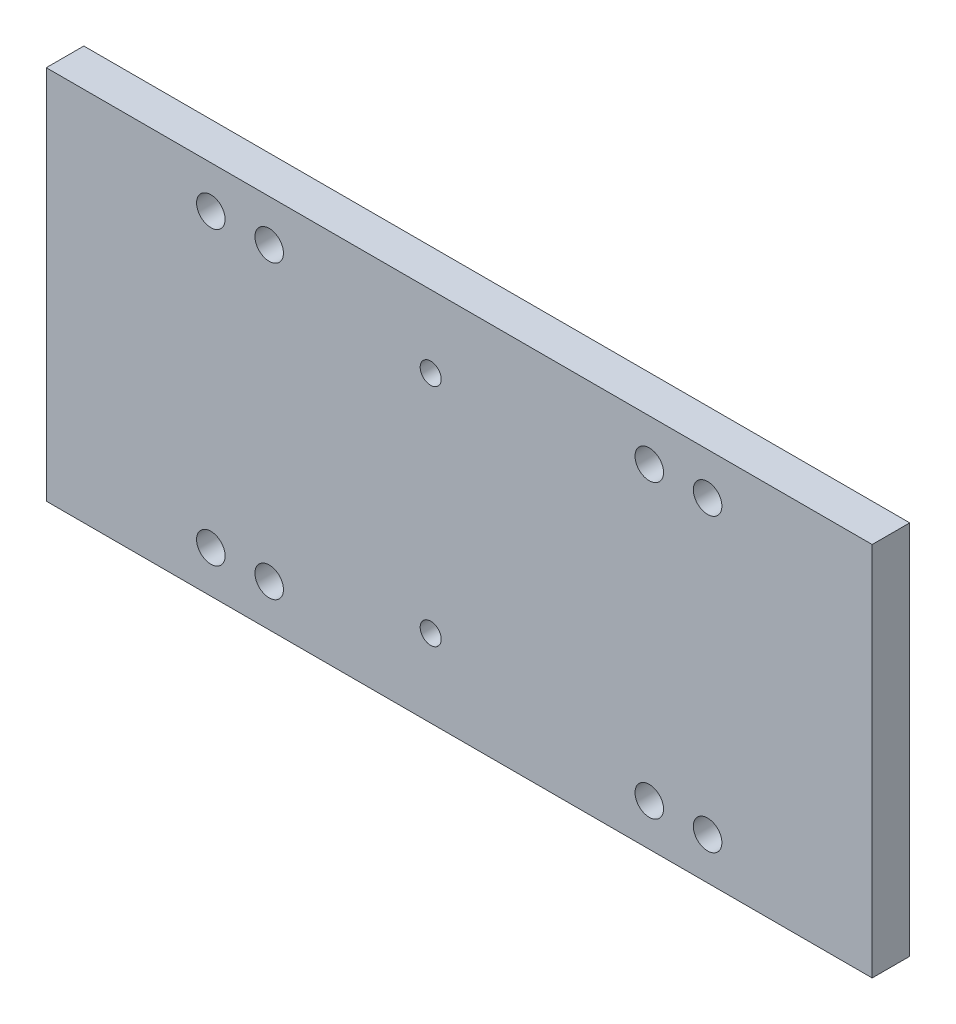
from build123d import *

# Parameters (mm, degrees)
SKETCH1_W           = 139.7
SKETCH1_H           = 63.5
BOSS_EXTRUDE1_DEPTH = 6.35
SKETCH2_R           = 1.778
CUT_EXTRUDE1_DEPTH  = 6.35
SKETCH3_R           = 2.413
CUT_EXTRUDE2_DEPTH  = 6.35


with BuildPart() as part:
    # Sketch1 → Boss-Extrude1 (new body)
    with BuildSketch(Plane.XY):
        with Locations((69.85, 31.75)):
            Rectangle(SKETCH1_W, SKETCH1_H)
    extrude(amount=BOSS_EXTRUDE1_DEPTH)

    # Sketch2 → Cut-Extrude1 (cut)
    with BuildSketch(Plane(origin=(0, 0, 0), x_dir=(-1, 0, 0), z_dir=(0, 0, -1))):
        with Locations((-65.024, 13.15775)):
            Circle(SKETCH2_R)
        with Locations((-65.024, 51.25775)):
            Circle(SKETCH2_R)
    extrude(amount=-CUT_EXTRUDE1_DEPTH, mode=Mode.SUBTRACT)

    # Sketch3 → Cut-Extrude2 (cut)
    with BuildSketch(Plane(origin=(0, 0, 0), x_dir=(-1, 0, 0), z_dir=(0, 0, -1))):
        with Locations((-111.865, 7.1)):
            Circle(SKETCH3_R)
        with Locations((-101.995, 7.1)):
            Circle(SKETCH3_R)
        with Locations((-111.865, 56.4)):
            Circle(SKETCH3_R)
        with Locations((-101.995, 56.4)):
            Circle(SKETCH3_R)
        with Locations((-37.705, 56.4)):
            Circle(SKETCH3_R)
        with Locations((-27.835, 56.4)):
            Circle(SKETCH3_R)
        with Locations((-27.835, 7.1)):
            Circle(SKETCH3_R)
        with Locations((-37.705, 7.1)):
            Circle(SKETCH3_R)
    extrude(amount=-CUT_EXTRUDE2_DEPTH, mode=Mode.SUBTRACT)


solid = part.part
